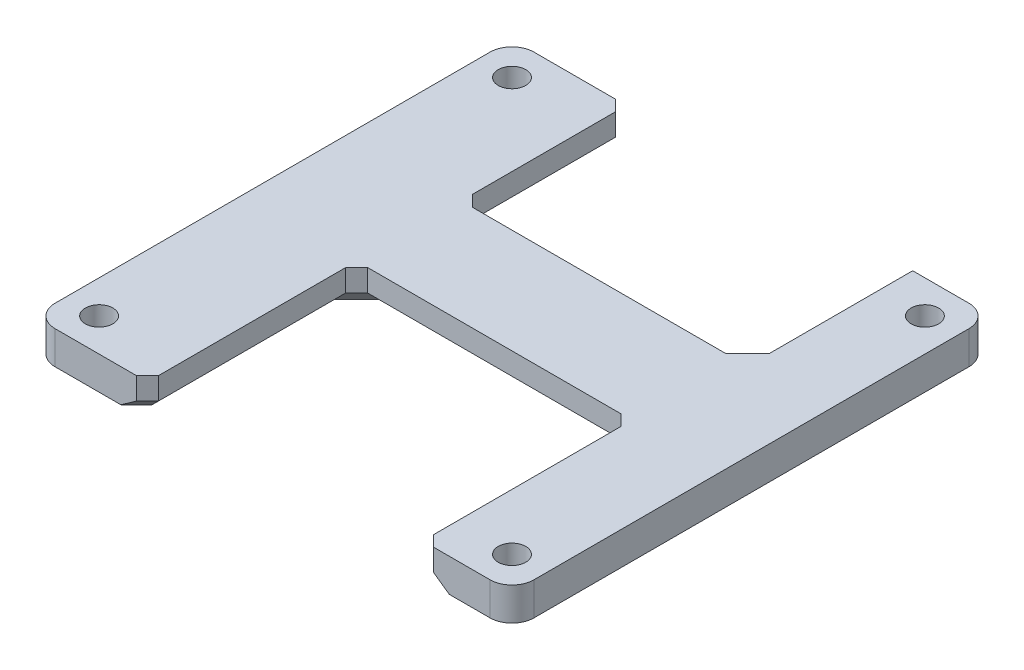
from build123d import *

# Parameters (mm, degrees)
CROQUIS1_R              = 1.25
SALIENTE_EXTRUIR1_DEPTH = 3
CHAFL_N1_SIZE           = 1


with BuildPart() as part:
    # Croquis1 → Saliente-Extruir1 (new body)
    with BuildSketch(Plane(origin=(0, 0, 0), x_dir=(1, 0, 0), z_dir=(0, 1, 0))):
        with BuildLine():
            Line((-31.108771954, -40.5), (-30.108771954, -39.5))
            Line((-30.108771954, -39.5), (-30.108771954, -21.5))
            Line((-30.108771954, -21.5), (-5.108771954, -21.5))
            Line((-5.108771954, -21.5), (-5.108771954, -39.5))
            Line((-5.108771954, -39.5), (-4.108771954, -40.5))
            Line((-4.108771954, -40.5), (1, -40.5))
            ThreePointArc((1, -40.5), (2.414213562, -39.914213562), (3, -38.5))
            Line((3, -38.5), (3, 1))
            ThreePointArc((3, 1), (2.414213562, 2.414213562), (1, 3))
            Line((1, 3), (-4.108771954, 3))
            Line((-4.108771954, 3), (-5.108771954, 2))
            Line((-5.108771954, 2), (-5.108771954, -11))
            Line((-5.108771954, -11), (-6.108771954, -12))
            Line((-6.108771954, -12), (-29.108771954, -12))
            Line((-29.108771954, -12), (-30.108771954, -11))
            Line((-30.108771954, -11), (-30.108771954, 2))
            Line((-30.108771954, 2), (-31.108771954, 3))
            Line((-31.108771954, 3), (-38.5, 3))
            ThreePointArc((-38.5, 3), (-39.914213562, 2.414213562), (-40.5, 1))
            Line((-40.5, 1), (-40.5, -38.5))
            ThreePointArc((-40.5, -38.5), (-39.914213562, -39.914213562), (-38.5, -40.5))
            Line((-38.5, -40.5), (-31.108771954, -40.5))
        make_face()
        with Locations((-37.5, -37.5)):
            Circle(CROQUIS1_R, mode=Mode.SUBTRACT)
        with Locations((-37.5, 0)):
            Circle(CROQUIS1_R, mode=Mode.SUBTRACT)
        with Locations((0, -37.5)):
            Circle(CROQUIS1_R, mode=Mode.SUBTRACT)
        Circle(CROQUIS1_R, mode=Mode.SUBTRACT)
    extrude(amount=SALIENTE_EXTRUIR1_DEPTH)

    # Chaflán1
    chafl_n1_edges = [part.edges().sort_by_distance(p)[0] for p in [
        (-4.608771954, 0, 40),
        (-30.608771954, 0, 40),
        (-4.608771954, 0, -2.5),
        (-5.108771954, 3, 4.5),
        (-30.608771954, 0, -2.5),
        (-5.608771954, 0, 11.5),
        (-30.108771954, 0, 4.5),
        (-29.608771954, 0, 11.5),
        (-17.608771954, 0, 12),
        (-5.108771954, 0, 30.5),
        (-30.108771954, 0, 30.5),
        (-5.108771954, 1.5, 21.5),
        (-17.608771954, 0, 21.5),
        (-30.108771954, 1.5, 21.5),
    ]]
    chamfer(chafl_n1_edges, length=CHAFL_N1_SIZE)


solid = part.part
